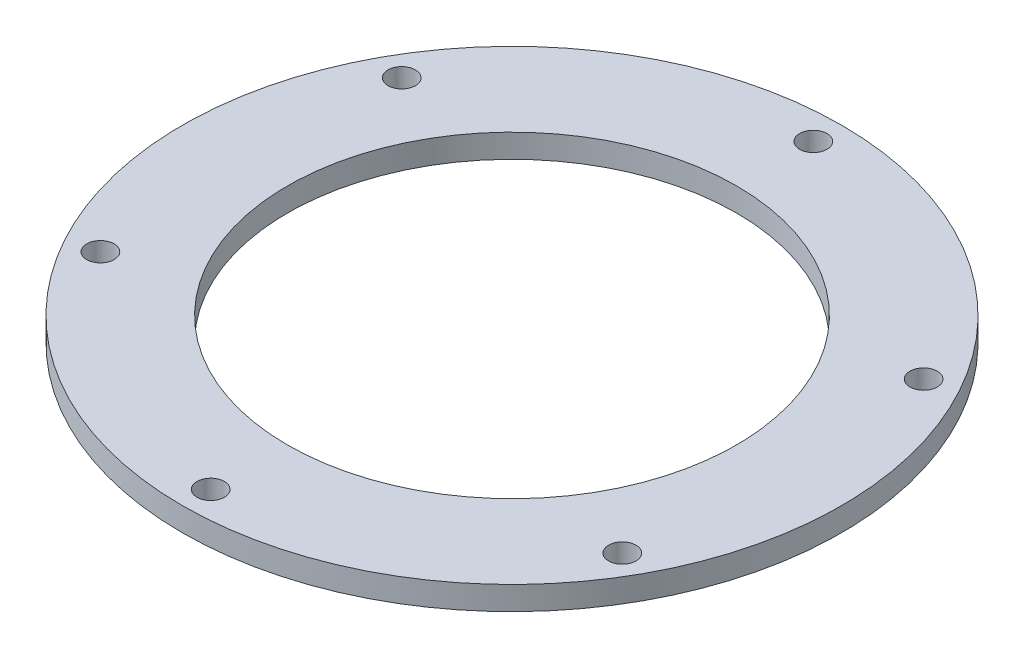
from build123d import *

# Parameters (mm, degrees)
SKETCH1_R                 = 44.45
SKETCH1_R_2               = 30.275917709
BOSS_EXTRUDE1_DEPTH       = 3.175
F_6_CLEARANCE_HOLE1_D     = 3.6957
F_6_CLEARANCE_HOLE1_DEPTH = 3.176
CIRPATTERN1_COUNT         = 6


with BuildPart() as part:
    # Sketch1 → Boss-Extrude1 (new body)
    with BuildSketch(Plane(origin=(0, 0, 0), x_dir=(1, 0, 0), z_dir=(0, 1, 0))):
        Circle(SKETCH1_R)
        Circle(SKETCH1_R_2, mode=Mode.SUBTRACT)
    extrude(amount=BOSS_EXTRUDE1_DEPTH)

    # #6 Clearance Hole1
    with Locations(Plane(origin=(0, 3.175, 0), x_dir=(1, 0, 0), z_dir=(0, 1, 0))):
        with Locations((0, 40.64)):
            f_6_clearance_hole1 = Hole(F_6_CLEARANCE_HOLE1_D / 2, depth=F_6_CLEARANCE_HOLE1_DEPTH)

    # CirPattern1: #6 Clearance Hole1 ×6 about axis
    cirpattern1_axis = Axis((0, 0, 0), (0, 1, 0))
    for i in range(1, CIRPATTERN1_COUNT):
        add(f_6_clearance_hole1.rotate(cirpattern1_axis, i * 360 / CIRPATTERN1_COUNT), mode=Mode.SUBTRACT)


solid = part.part
